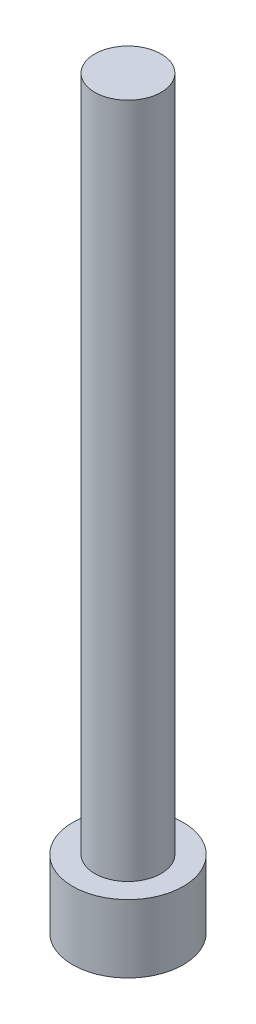
from build123d import *

# Parameters (mm, degrees)
SKETCH1_R           = 2.8575
BOSS_EXTRUDE1_DEPTH = 3.5052
CUT_EXTRUDE1_DEPTH  = 1.9558
SKETCH3_R           = 1.7145
BOSS_EXTRUDE2_DEPTH = 34.925


with BuildPart() as part:
    # Sketch1 → Boss-Extrude1 (new body)
    with BuildSketch(Plane(origin=(0, 0, 0), x_dir=(1, 0, 0), z_dir=(0, 1, 0))):
        Circle(SKETCH1_R)
    extrude(amount=BOSS_EXTRUDE1_DEPTH)

    # Sketch2 → Cut-Extrude1 (cut)
    with BuildSketch(Plane.XZ):
        Polygon((1.603951217, 0), (0.801975608, 1.3890625), (-0.801975608, 1.3890625), (-1.603951217, 0), (-0.801975608, -1.3890625), (0.801975608, -1.3890625), align=None)
    extrude(amount=-CUT_EXTRUDE1_DEPTH, mode=Mode.SUBTRACT)

    # Sketch3 → Boss-Extrude2 (add)
    with BuildSketch(Plane(origin=(0, 3.5052, 0), x_dir=(1, 0, 0), z_dir=(0, 1, 0))):
        Circle(SKETCH3_R)
    extrude(amount=BOSS_EXTRUDE2_DEPTH)


solid = part.part
